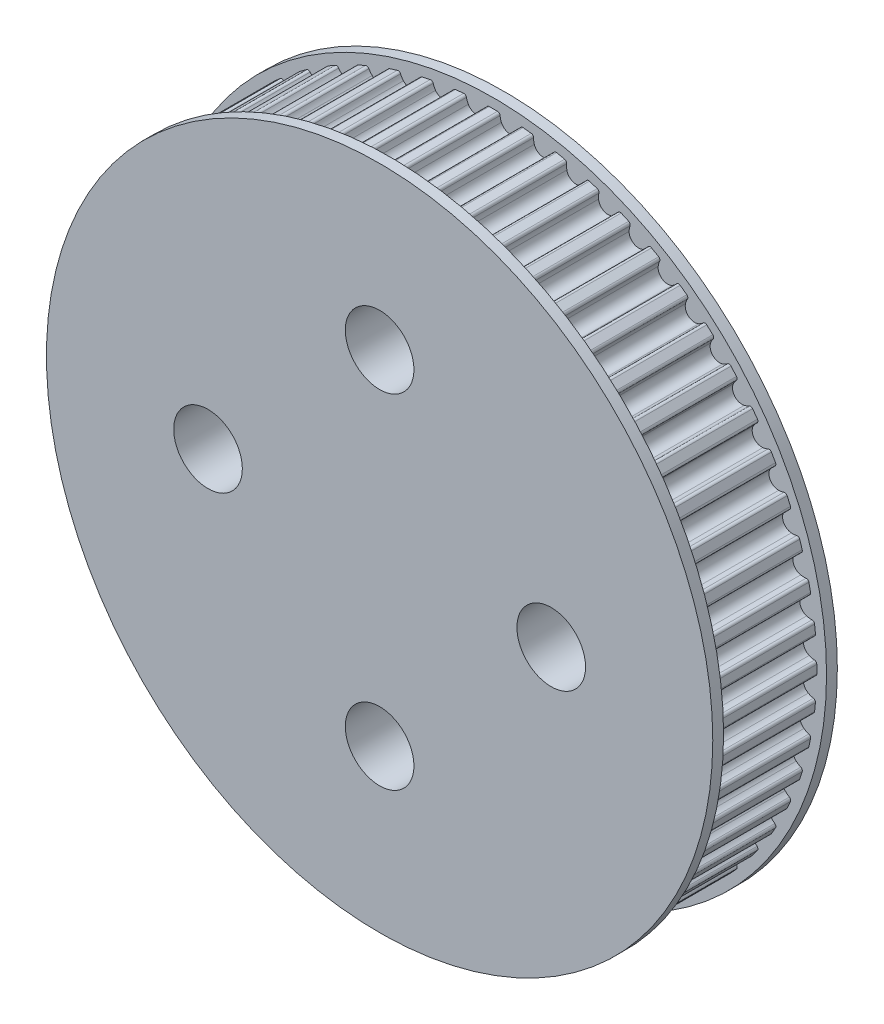
from build123d import *

# Parameters (mm, degrees)
SKETCH2_R           = 19.1
BOSS_EXTRUDE1_DEPTH = 6
CUT_EXTRUDE1_DEPTH  = 6
CIRPATTERN3_COUNT   = 60
SKETCH7_R           = 19.415
BOSS_EXTRUDE3_DEPTH = 0.63
SKETCH8_R           = 2
CUT_EXTRUDE4_DEPTH  = 8.26


with BuildPart() as part:
    # Sketch2 → Boss-Extrude1 (new body)
    with BuildSketch(Plane.XY):
        Circle(SKETCH2_R)
    extrude(amount=BOSS_EXTRUDE1_DEPTH)

    # Sketch3 → Cut-Extrude1 (cut)
    with BuildSketch(Plane.XY.offset(6)):
        with BuildLine():
            Line((0, 18.846), (0.239580256, 18.846))
            ThreePointArc((0.239580256, 18.846), (0.341062668, 18.806459586), (0.389042992, 18.708684268))
            ThreePointArc((0.389042992, 18.708684268), (0.414828788, 18.552678674), (0.46488297, 18.402687902))
            ThreePointArc((0.46488297, 18.402687902), (0.946757448, 18.065208284), (1.461268394, 18.350469555))
            ThreePointArc((1.461268394, 18.350469555), (1.526726679, 18.494406574), (1.568678243, 18.646862204))
            ThreePointArc((1.568678243, 18.646862204), (1.626616029, 18.739086589), (1.731675608, 18.767802596))
            Line((1.731675608, 18.767802596), (1.969943419, 18.74275964))
            Line((1.969943419, 18.74275964), (1.996493648, 18.995368202))
            ThreePointArc((1.996493648, 18.995368202), (0.999616764, 19.073824114), (0, 19.1))
            Line((0, 19.1), (0, 18.846))
        make_face()
    cut_extrude1 = extrude(amount=-CUT_EXTRUDE1_DEPTH, mode=Mode.SUBTRACT)

    # CirPattern3: Cut-Extrude1 ×60 about axis
    cirpattern3_axis = Axis((0, 0, 0), (0, 0, 1))
    for i in range(1, CIRPATTERN3_COUNT):
        add(cut_extrude1.rotate(cirpattern3_axis, i * 360 / CIRPATTERN3_COUNT), mode=Mode.SUBTRACT)

    # Sketch7 → Boss-Extrude3 (add)
    with BuildSketch(Plane.XY.offset(6)):
        Circle(SKETCH7_R)
    boss_extrude3 = extrude(amount=BOSS_EXTRUDE3_DEPTH)

    # Mirror2: Boss-Extrude3 across plane
    add(boss_extrude3.mirror(Plane(origin=(0, 0, 3), x_dir=(1, 0, 0), z_dir=(0, 0, -1))))

    # Sketch8 → Cut-Extrude4 (cut, through all)
    with BuildSketch(Plane.XY.offset(6.63)):
        with Locations((0, 10)):
            Circle(SKETCH8_R)
        with Locations((10, 0)):
            Circle(SKETCH8_R)
        with Locations((0, -10)):
            Circle(SKETCH8_R)
        with Locations((-10, 0)):
            Circle(SKETCH8_R)
    extrude(amount=-CUT_EXTRUDE4_DEPTH, mode=Mode.SUBTRACT)


solid = part.part
